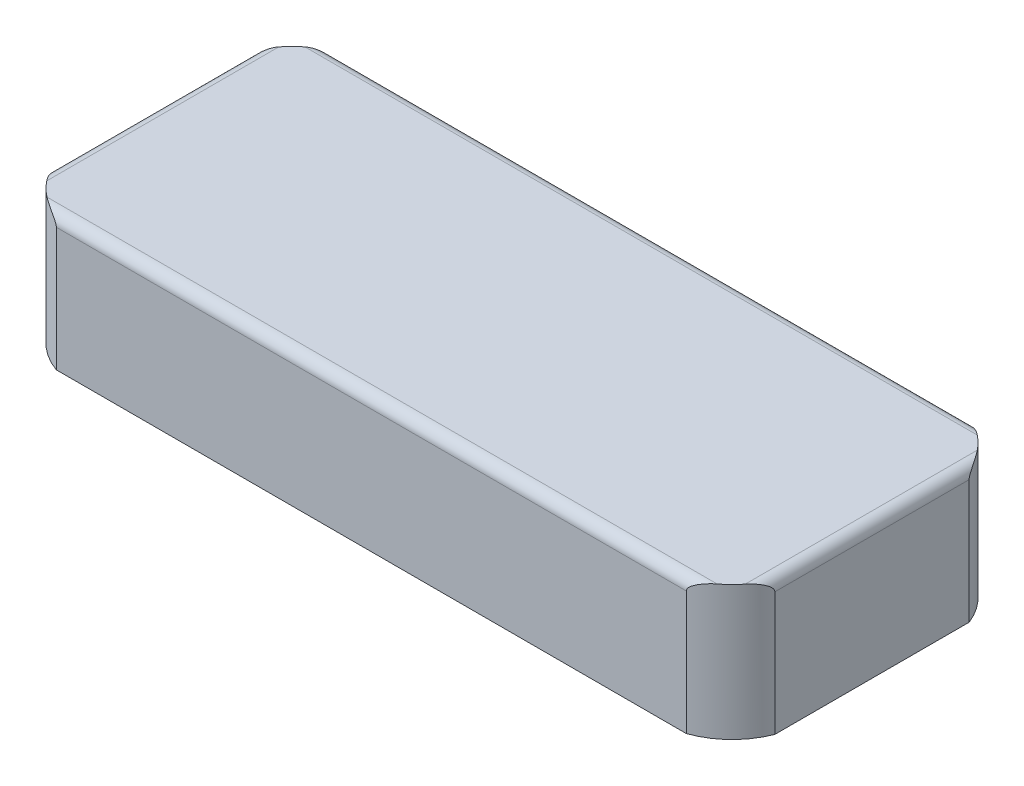
from build123d import *

# Parameters (mm, degrees)
SKETCH1_W                  = 431.8
SKETCH1_H                  = 171.45
BOSS_EXTRUDE1_DEPTH        = 85.725
CUT_EXTRUDE1_DEPTH         = 73.025
FILLET3_R                  = 44.45
F_0_25_OFF_THE_TOP_DEPTH   = 6.35
SKETCH4_W                  = 431.8
SKETCH4_H                  = 79.375
F_0_12_OFF_THE_SIDE_DEPTH  = 2.54
SKETCH5_W                  = 168.91
SKETCH5_H                  = 79.375
F_0_12_OFF_THE_FRONT_DEPTH = 3.048
SKETCH6_W                  = 428.752
SKETCH6_H                  = 79.375
CUT_EXTRUDE5_DEPTH         = 3.048
SKETCH7_W                  = 165.862
SKETCH7_H                  = 79.375
CUT_EXTRUDE6_DEPTH         = 3.048
FILLET5_R                  = 6.35


with BuildPart() as part:
    # Sketch1 → Boss-Extrude1 (new body)
    with BuildSketch(Plane(origin=(0, 0, 0), x_dir=(1, 0, 0), z_dir=(0, 1, 0))):
        Rectangle(SKETCH1_W, SKETCH1_H)
    extrude(amount=BOSS_EXTRUDE1_DEPTH)

    # Sketch2 → Cut-Extrude1 (cut)
    with BuildSketch(Plane.XZ):
        with BuildLine():
            Line((162.16885638, 76.686434381), (-162.16885638, 76.686434381))
            ThreePointArc((-162.16885638, 76.686434381), (-193.771281353, 63.596281353), (-206.861434381, 31.99385638))
            Line((-206.861434381, 31.99385638), (-206.861434381, -31.99385638))
            ThreePointArc((-206.861434381, -31.99385638), (-193.771281353, -63.596281353), (-162.16885638, -76.686434381))
            Line((-162.16885638, -76.686434381), (162.16885638, -76.686434381))
            ThreePointArc((162.16885638, -76.686434381), (193.771281353, -63.596281353), (206.861434381, -31.99385638))
            Line((206.861434381, -31.99385638), (206.861434381, 31.99385638))
            ThreePointArc((206.861434381, 31.99385638), (193.771281353, 63.596281353), (162.16885638, 76.686434381))
        make_face()
    extrude(amount=-CUT_EXTRUDE1_DEPTH, mode=Mode.SUBTRACT)

    # Fillet3
    fillet3_edges = [part.edges().sort_by_distance(p)[0] for p in [
        (215.9, 42.8625, 85.725),
        (-215.9, 42.8625, 85.725),
        (-215.9, 42.8625, -85.725),
        (215.9, 42.8625, -85.725),
    ]]
    fillet(fillet3_edges, radius=FILLET3_R)

    # Sketch3 → 0.25 off the top (cut)
    with BuildSketch(Plane(origin=(0, 85.725, 0), x_dir=(1, 0, 0), z_dir=(0, 1, 0))):
        with BuildLine():
            Line((215.9, -41.275), (215.9, 41.275))
            ThreePointArc((215.9, 41.275), (202.880896424, 72.705896424), (171.45, 85.725))
            Line((171.45, 85.725), (-171.45, 85.725))
            ThreePointArc((-171.45, 85.725), (-202.880896424, 72.705896424), (-215.9, 41.275))
            Line((-215.9, 41.275), (-215.9, -41.275))
            ThreePointArc((-215.9, -41.275), (-202.880896424, -72.705896424), (-171.45, -85.725))
            Line((-171.45, -85.725), (171.45, -85.725))
            ThreePointArc((171.45, -85.725), (202.880896424, -72.705896424), (215.9, -41.275))
        make_face()
    extrude(amount=-F_0_25_OFF_THE_TOP_DEPTH, mode=Mode.SUBTRACT)

    # Sketch4 → 0.12 off the side (cut)
    with BuildSketch(Plane.XY.offset(85.725)):
        with Locations((0, 39.6875)):
            Rectangle(SKETCH4_W, SKETCH4_H)
    extrude(amount=-F_0_12_OFF_THE_SIDE_DEPTH, mode=Mode.SUBTRACT)

    # Sketch5 → 0.12 off the front (cut)
    with BuildSketch(Plane.ZY.offset(215.9)):
        with Locations((-1.27, 39.6875)):
            Rectangle(SKETCH5_W, SKETCH5_H)
    extrude(amount=-F_0_12_OFF_THE_FRONT_DEPTH, mode=Mode.SUBTRACT)

    # Sketch6 → Cut-Extrude5 (cut)
    with BuildSketch(Plane(origin=(0, 0, -85.725), x_dir=(-1, 0, 0), z_dir=(0, 0, -1))):
        with Locations((-1.524, 39.6875)):
            Rectangle(SKETCH6_W, SKETCH6_H)
    extrude(amount=-CUT_EXTRUDE5_DEPTH, mode=Mode.SUBTRACT)

    # Sketch7 → Cut-Extrude6 (cut)
    with BuildSketch(Plane(origin=(215.9, 0, 0), x_dir=(0, 0, -1), z_dir=(1, 0, 0))):
        with Locations((-0.254, 39.6875)):
            Rectangle(SKETCH7_W, SKETCH7_H)
    extrude(amount=-CUT_EXTRUDE6_DEPTH, mode=Mode.SUBTRACT)

    # Fillet5
    fillet5_edges = [part.edges().sort_by_distance(p)[0] for p in [
        (-212.852, 79.375, 0),
        (0, 79.375, -82.677),
        (212.852, 79.375, 0),
        (0, 79.375, 83.185),
    ]]
    fillet(fillet5_edges, radius=FILLET5_R)


solid = part.part
